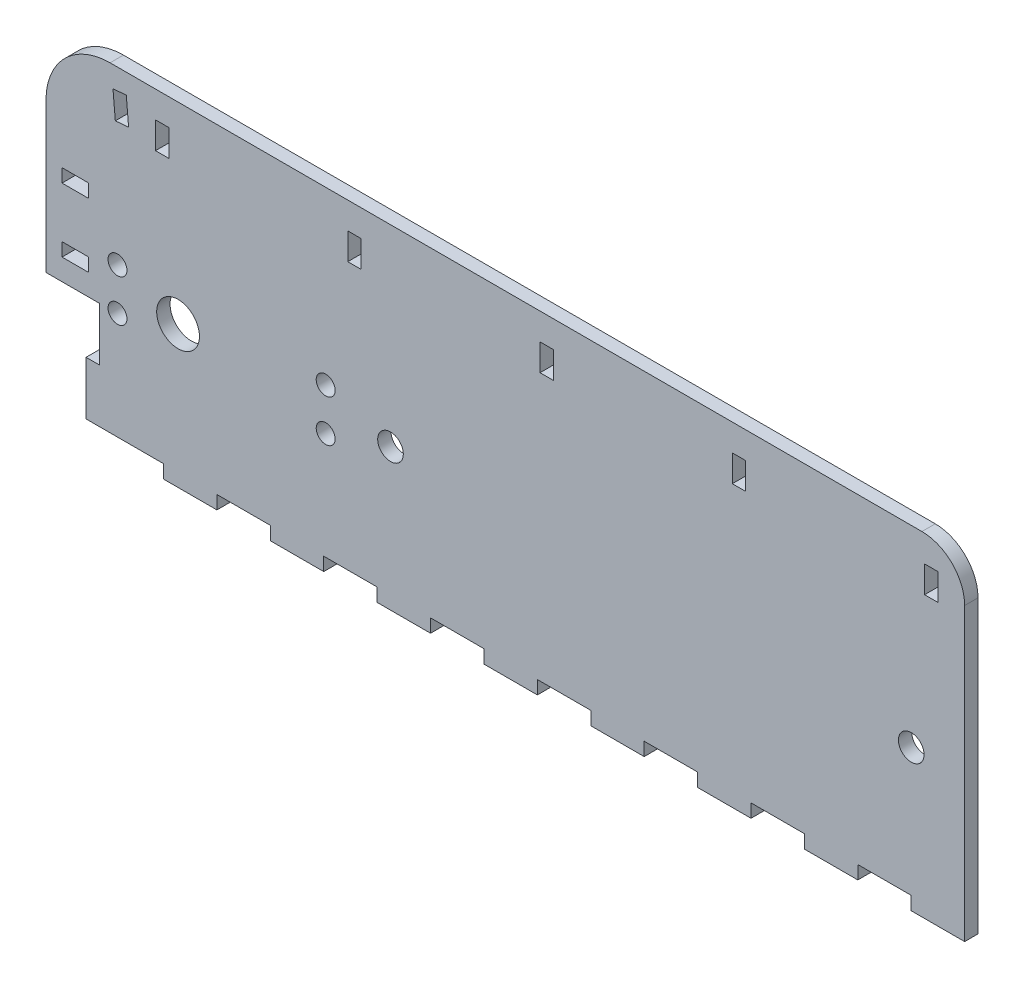
from build123d import *

# Parameters (mm, degrees)
SKETCH1_W           = 228.6
SKETCH1_H           = 76.2
SKETCH1_R           = 3.048
SKETCH1_R_2         = 5.08
BOSS_EXTRUDE1_DEPTH = 3.175
SKETCH2_W           = 12.7
SKETCH2_H           = 3.175
BOSS_EXTRUDE2_DEPTH = 3.175
SKETCH3_W           = 22.86
SKETCH3_H           = 25.4
CUT_EXTRUDE1_DEPTH  = 4.175
SKETCH4_W           = 3.175
SKETCH4_H           = 12.7
BOSS_EXTRUDE3_DEPTH = 3.175
SKETCH6_R           = 2.25
CUT_EXTRUDE2_DEPTH  = 4.175
SKETCH8_W           = 10.16
SKETCH8_H           = 50.8
CUT_EXTRUDE3_DEPTH  = 4.175
SKETCH12_W          = 3.175
SKETCH12_H          = 6.35
CUT_EXTRUDE5_DEPTH  = 3.175
CUT_EXTRUDE6_DEPTH  = 4.175
SKETCH14_W          = 6.35
SKETCH14_H          = 3.175
CUT_EXTRUDE7_DEPTH  = 4.175
CUT_EXTRUDE8_DEPTH  = 4.175
CUT_EXTRUDE9_DEPTH  = 4.175


with BuildPart() as part:
    # Sketch1 → Boss-Extrude1 (new body)
    with BuildSketch(Plane.XY):
        with Locations((114.3, 38.1)):
            Rectangle(SKETCH1_W, SKETCH1_H)
        with Locations((215.9, 30.48)):
            Circle(SKETCH1_R, mode=Mode.SUBTRACT)
        with Locations((92.075, 30.48)):
            Circle(SKETCH1_R, mode=Mode.SUBTRACT)
        with Locations((41.56075, 30.48)):
            Circle(SKETCH1_R_2, mode=Mode.SUBTRACT)
    extrude(amount=BOSS_EXTRUDE1_DEPTH)

    # Sketch2 → Boss-Extrude2 (add)
    with BuildSketch(Plane.XZ):
        with Locations((222.25, 1.5875)):
            Rectangle(SKETCH2_W, SKETCH2_H)
        with Locations((196.85, 1.5875)):
            Rectangle(SKETCH2_W, SKETCH2_H)
        with Locations((171.45, 1.5875)):
            Rectangle(SKETCH2_W, SKETCH2_H)
        with Locations((146.05, 1.5875)):
            Rectangle(SKETCH2_W, SKETCH2_H)
        with Locations((120.65, 1.5875)):
            Rectangle(SKETCH2_W, SKETCH2_H)
        with Locations((95.25, 1.5875)):
            Rectangle(SKETCH2_W, SKETCH2_H)
        with Locations((69.85, 1.5875)):
            Rectangle(SKETCH2_W, SKETCH2_H)
        with Locations((44.45, 1.5875)):
            Rectangle(SKETCH2_W, SKETCH2_H)
    extrude(amount=BOSS_EXTRUDE2_DEPTH)

    # Sketch3 → Cut-Extrude1 (cut, through all)
    with BuildSketch(Plane(origin=(0, 0, 0), x_dir=(-1, 0, 0), z_dir=(0, 0, -1))):
        with Locations((-11.43, 12.7)):
            Rectangle(SKETCH3_W, SKETCH3_H)
    extrude(amount=-CUT_EXTRUDE1_DEPTH, mode=Mode.SUBTRACT)

    # Sketch4 → Boss-Extrude3 (add)
    with BuildSketch(Plane.ZY.offset(-22.86)):
        with Locations((1.5875, 6.35)):
            Rectangle(SKETCH4_W, SKETCH4_H)
    extrude(amount=BOSS_EXTRUDE3_DEPTH)

    # Sketch6 → Cut-Extrude2 (cut, through all)
    with BuildSketch(Plane(origin=(0, 0, 0), x_dir=(-1, 0, 0), z_dir=(0, 0, -1))):
        with Locations((-27.16075, 35.48)):
            Circle(SKETCH6_R)
        with Locations((-27.16075, 25.48)):
            Circle(SKETCH6_R)
        with Locations((-76.66075, 35.48)):
            Circle(SKETCH6_R)
        with Locations((-76.66075, 25.48)):
            Circle(SKETCH6_R)
    extrude(amount=-CUT_EXTRUDE2_DEPTH, mode=Mode.SUBTRACT)

    # Sketch8 → Cut-Extrude3 (cut, through all)
    with BuildSketch(Plane.XY.offset(3.175)):
        with Locations((5.08, 50.8)):
            Rectangle(SKETCH8_W, SKETCH8_H)
    extrude(amount=-CUT_EXTRUDE3_DEPTH, mode=Mode.SUBTRACT)

    # Sketch12 → Cut-Extrude5 (cut)
    with BuildSketch(Plane(origin=(0, 0, 0), x_dir=(-1, 0, 0), z_dir=(0, 0, -1))):
        with Locations((-220.6625, 66.675)):
            Rectangle(SKETCH12_W, SKETCH12_H)
        with Locations((-174.9425, 66.675)):
            Rectangle(SKETCH12_W, SKETCH12_H)
        with Locations((-129.2225, 66.675)):
            Rectangle(SKETCH12_W, SKETCH12_H)
        with Locations((-83.5025, 66.675)):
            Rectangle(SKETCH12_W, SKETCH12_H)
        with Locations((-37.7825, 66.675)):
            Rectangle(SKETCH12_W, SKETCH12_H)
    extrude(amount=-CUT_EXTRUDE5_DEPTH, mode=Mode.SUBTRACT)

    # Sketch13 → Cut-Extrude6 (cut, through all)
    with BuildSketch(Plane.XY.offset(3.175)):
        with BuildLine():
            Line((10.16, 60.96), (10.16, 76.2))
            Line((10.16, 76.2), (25.4, 76.2))
            ThreePointArc((25.4, 76.2), (14.623692655, 71.736307345), (10.16, 60.96))
        make_face()
    extrude(amount=-CUT_EXTRUDE6_DEPTH, mode=Mode.SUBTRACT)

    # Sketch14 → Cut-Extrude7 (cut, through all)
    with BuildSketch(Plane.XY.offset(3.175)):
        with Locations((17.145, 32.0675)):
            Rectangle(SKETCH14_W, SKETCH14_H)
        with Locations((17.145, 47.3075)):
            Rectangle(SKETCH14_W, SKETCH14_H)
    extrude(amount=-CUT_EXTRUDE7_DEPTH, mode=Mode.SUBTRACT)

    # Sketch15 → Cut-Extrude8 (cut, through all)
    with BuildSketch(Plane.XY.offset(3.175)):
        Polygon((26.639339978, 64.870175511), (26.085901012, 71.196011844), (29.248819178, 71.472731328), (29.802258145, 65.146894995), align=None)
    extrude(amount=-CUT_EXTRUDE8_DEPTH, mode=Mode.SUBTRACT)

    # Sketch16 → Cut-Extrude9 (cut, through all)
    with BuildSketch(Plane.XY.offset(3.175)):
        with BuildLine():
            Line((218.44, 76.2), (228.6, 76.2))
            Line((228.6, 76.2), (228.6, 66.04))
            ThreePointArc((228.6, 66.04), (225.624204897, 73.224204897), (218.44, 76.2))
        make_face()
    extrude(amount=-CUT_EXTRUDE9_DEPTH, mode=Mode.SUBTRACT)


solid = part.part
